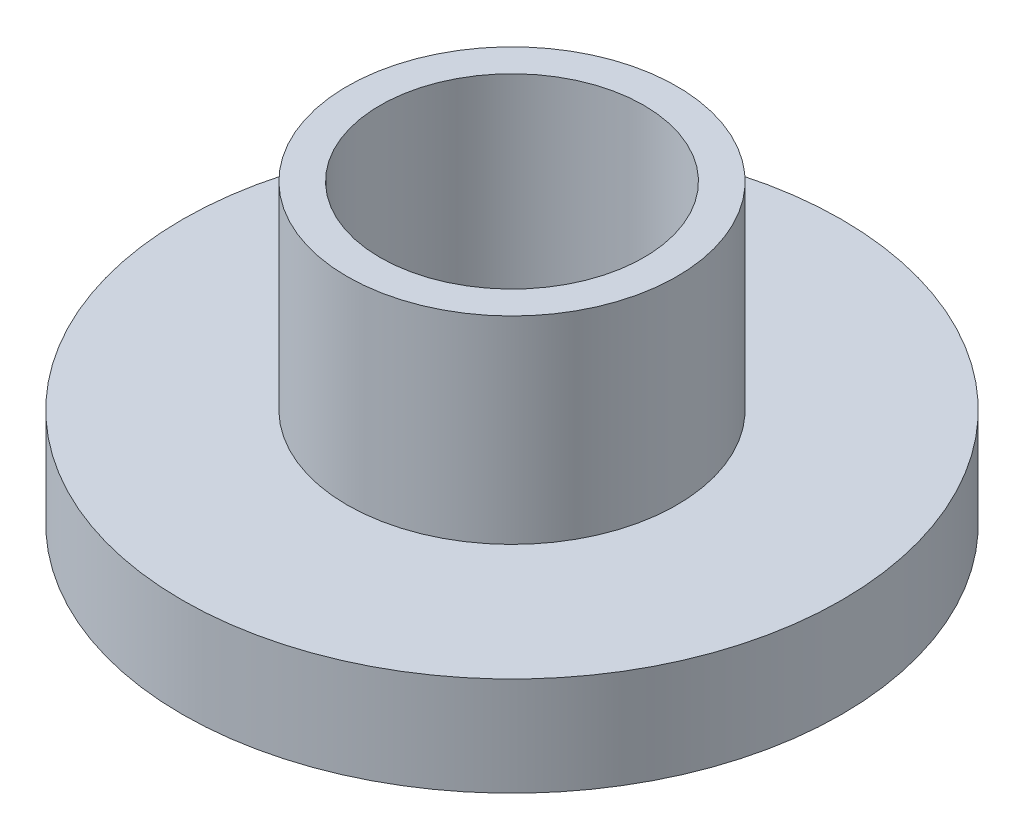
from build123d import *

# Parameters (mm, degrees)
SKETCH_1_R      = 5
SKETCH_1_R_2    = 2
EXTRUDE_1_DEPTH = 1.5
SKETCH_2_R      = 2.5
SKETCH_2_R_2    = 2
EXTRUDE_2_DEPTH = 3


with BuildPart() as part:
    # 草图1 → 凸台-拉伸1 (new body)
    with BuildSketch(Plane(origin=(0, 0, 0), x_dir=(1, 0, 0), z_dir=(0, 1, 0))):
        Circle(SKETCH_1_R)
        Circle(SKETCH_1_R_2, mode=Mode.SUBTRACT)
    extrude(amount=EXTRUDE_1_DEPTH)

    # 草图2 → 凸台-拉伸2 (add)
    with BuildSketch(Plane(origin=(0, 1.5, 0), x_dir=(1, 0, 0), z_dir=(0, 1, 0))):
        Circle(SKETCH_2_R)
        Circle(SKETCH_2_R_2, mode=Mode.SUBTRACT)
    extrude(amount=EXTRUDE_2_DEPTH)


solid = part.part
